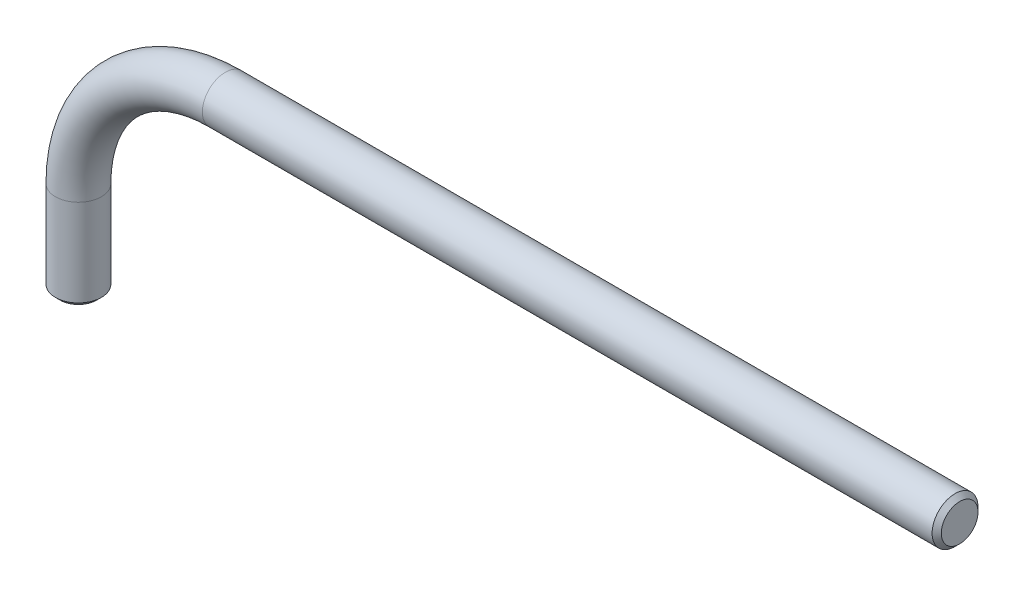
from build123d import *

# Parameters (mm, degrees)
SWEEP1_PROFILE_R = 2.5
CHAMFER1_SIZE    = 0.5


with BuildPart() as part:
    # Sweep1: sweep along a path in Sketch1
    with BuildLine(Plane.XY) as sweep1_path:
        Line((0, 0), (-80, 0))
        ThreePointArc((-80, 0), (-91.313708499, -4.686291501), (-96, -16))
        Line((-96, -16), (-96, -26))
    # Sweep1 profile (on start of the path) → Sweep1 (sweep)
    with BuildSketch(Plane(origin=(0, 0, 0), x_dir=(0, 0, -1), z_dir=(-1, 0, 0))):
        Circle(SWEEP1_PROFILE_R)
    sweep(path=sweep1_path.line)

    # Chamfer1
    chamfer1_edges = [part.edges().sort_by_distance(p)[0] for p in [
        (-96, -26, 2.5),
        (0, 0, 2.5),
    ]]
    chamfer(chamfer1_edges, length=CHAMFER1_SIZE)


solid = part.part
